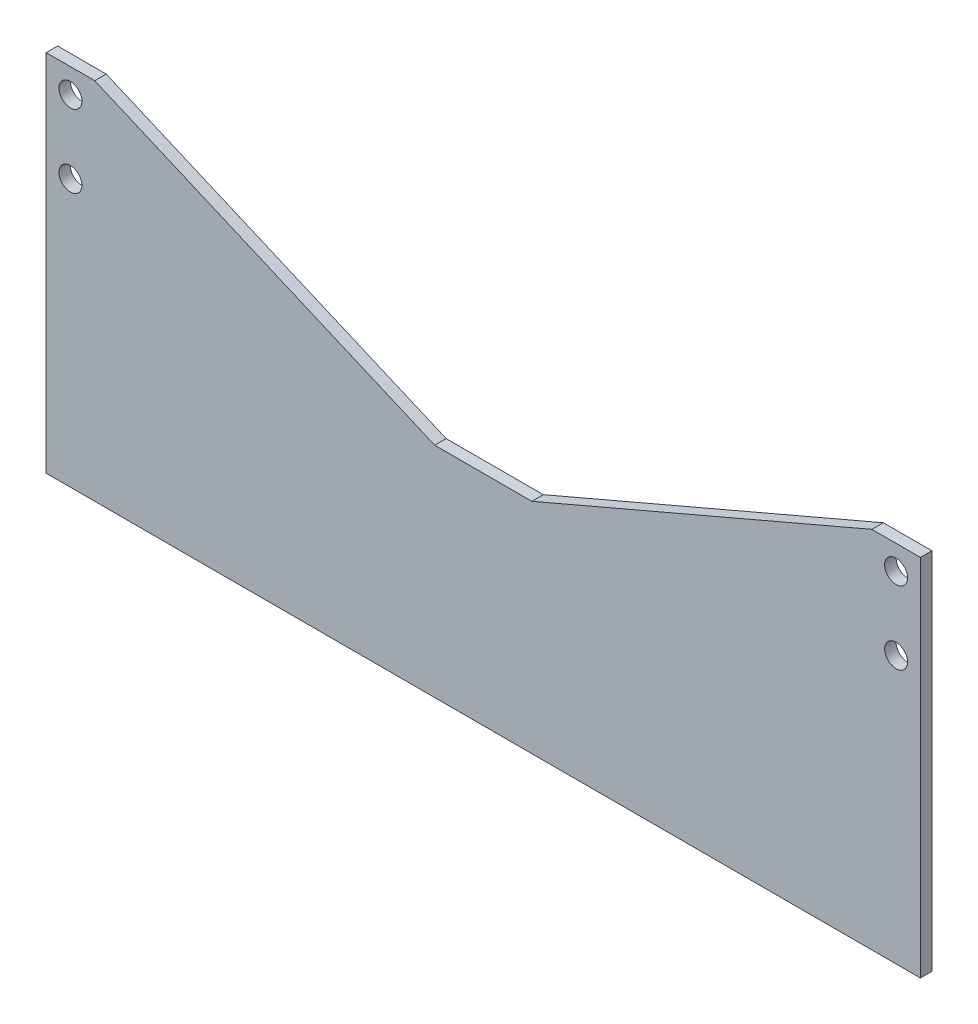
from build123d import *

# Parameters (mm, degrees)
SKETCH1_R           = 1.5
BOSS_EXTRUDE1_DEPTH = 0.75


with BuildPart() as part:
    # Sketch1 → Boss-Extrude1 (new body, symmetric)
    with BuildSketch(Plane.XY):
        Polygon((-57.15, -23.8125), (57.15, -23.8125), (57.15, 23.8125), (50.8, 23.8125), (6.35, 4.7625), (-6.35, 4.7625), (-50.8, 23.8125), (-57.15, 23.8125), align=None)
        with Locations((53.975, 20.6375)):
            Circle(SKETCH1_R, mode=Mode.SUBTRACT)
        with Locations((53.975, 11.1125)):
            Circle(SKETCH1_R, mode=Mode.SUBTRACT)
        with Locations((-53.975, 20.6375)):
            Circle(SKETCH1_R, mode=Mode.SUBTRACT)
        with Locations((-53.975, 11.1125)):
            Circle(SKETCH1_R, mode=Mode.SUBTRACT)
    extrude(amount=BOSS_EXTRUDE1_DEPTH, both=True)


solid = part.part
